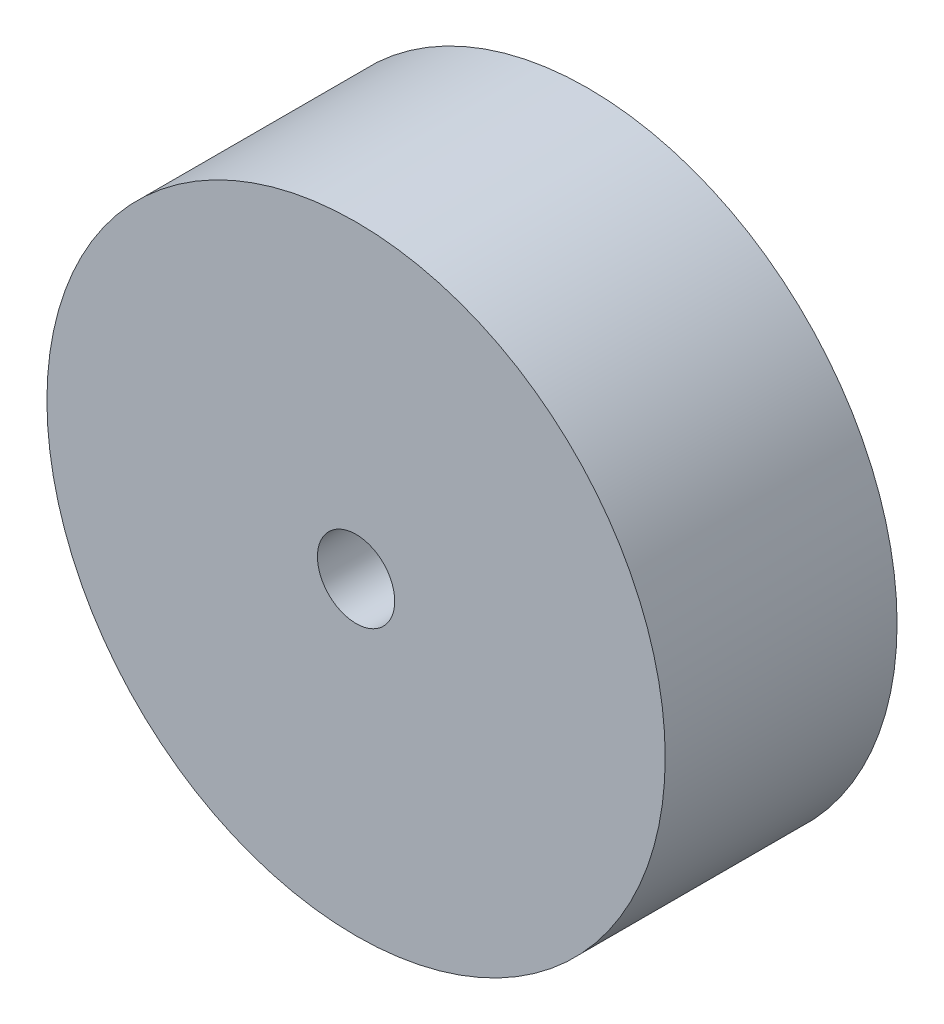
from build123d import *

# Parameters (mm, degrees)
SKETCH1_R           = 101.6
SKETCH1_R_2         = 12.7
BOSS_EXTRUDE1_DEPTH = 76.2


with BuildPart() as part:
    # Sketch1 → Boss-Extrude1 (new body)
    with BuildSketch(Plane.XY):
        Circle(SKETCH1_R)
        Circle(SKETCH1_R_2, mode=Mode.SUBTRACT)
    extrude(amount=BOSS_EXTRUDE1_DEPTH)


solid = part.part
